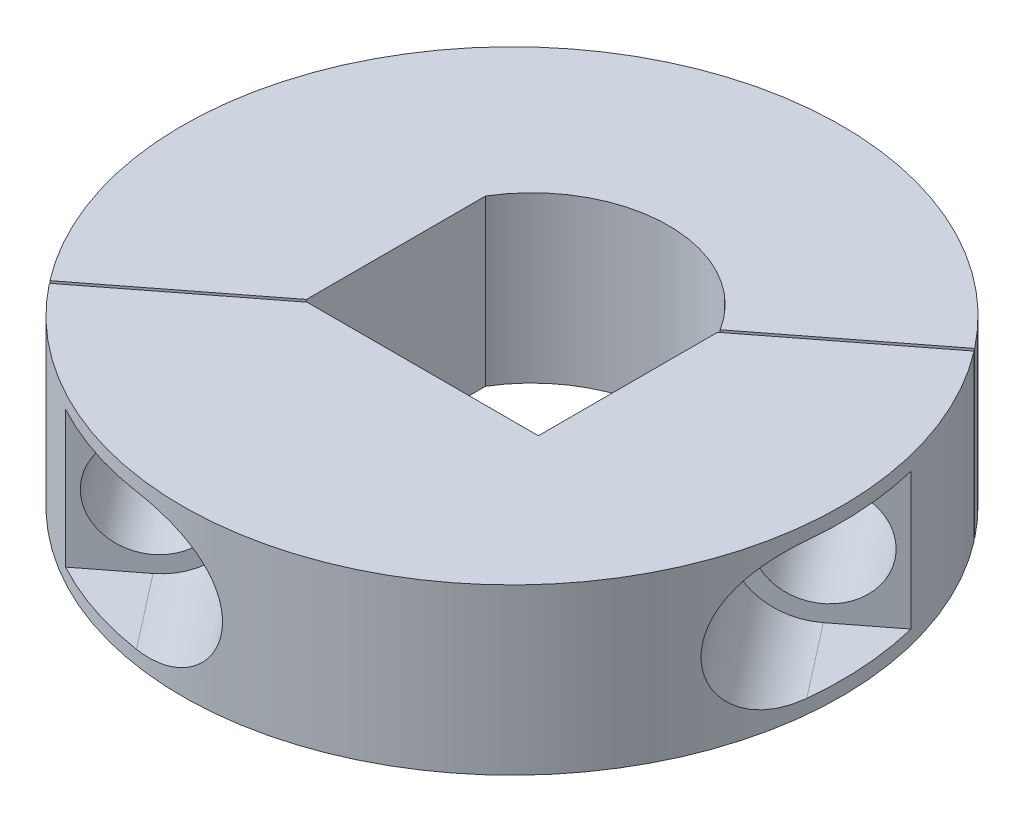
from build123d import *

# Parameters (mm, degrees)
SKETCH1_R               = 25.4
BOSS_EXTRUDE1_DEPTH     = 12.7
CUT_EXTRUDE1_DEPTH      = 13.7
CUT_EXTRUDE5_DEPTH      = 13.7
SKETCH5_R               = 4
CUT_EXTRUDE6_DEPTH      = 46.921867877
CUT_EXTRUDE6_DEPTH_BACK = 26.347867877
CUT_EXTRUDE7_DEPTH      = 26.347868027


with BuildPart() as part:
    # Sketch1 → Boss-Extrude1 (new body)
    with BuildSketch(Plane(origin=(0, 0, 0), x_dir=(1, 0, 0), z_dir=(0, 1, 0))):
        Circle(SKETCH1_R)
    extrude(amount=BOSS_EXTRUDE1_DEPTH)

    # Sketch2 → Cut-Extrude1 (cut, through all)
    with BuildSketch(Plane(origin=(0, 12.7, 0), x_dir=(1, 0, 0), z_dir=(0, 1, 0))):
        with BuildLine():
            Line((-9.017, -6.985), (9.017, -6.985))
            Line((9.017, -6.985), (9.017, 6.985))
            ThreePointArc((9.017, 6.985), (0, 12.065), (-9.017, 6.985))
            Line((-9.017, 6.985), (-9.017, -6.985))
        make_face()
    extrude(amount=-CUT_EXTRUDE1_DEPTH, mode=Mode.SUBTRACT)

    # Sketch4 → Cut-Extrude5 (cut, through all)
    with BuildSketch(Plane(origin=(0, 12.7, 0), x_dir=(1, 0, 0), z_dir=(0, 1, 0))):
        with BuildLine():
            Line((20.001939718, 15.655108033), (-20.157488744, -15.454308381))
            ThreePointArc((-20.157488744, -15.454308381), (-20.079965232, -15.554902645), (-20.001939718, -15.655108033))
            Line((-20.001939718, -15.655108033), (20.157488744, 15.454308381))
            ThreePointArc((20.157488744, 15.454308381), (20.079965232, 15.554902645), (20.001939718, 15.655108033))
        make_face()
    extrude(amount=-CUT_EXTRUDE5_DEPTH, mode=Mode.SUBTRACT)

    # Sketch5 → Cut-Extrude6 (cut, two sides)
    with BuildSketch(Plane(origin=(6.299735571, 0, 8.132385919), x_dir=(-0.790549812, 0, 0.612397742), z_dir=(-0.612397742, 0, -0.790549812))) as cut_extrude6_sk:
        with Locations((-18.409741518, 6.35)):
            Circle(SKETCH5_R)
        with Locations((18.409741518, 6.35)):
            Circle(SKETCH5_R)
    extrude(amount=CUT_EXTRUDE6_DEPTH, mode=Mode.SUBTRACT)
    extrude(cut_extrude6_sk.sketch, amount=-CUT_EXTRUDE6_DEPTH_BACK, mode=Mode.SUBTRACT)

    # Sketch6 → Cut-Extrude7 (cut, through all)
    with BuildSketch(Plane(origin=(6.299735571, 0, 8.132385919), x_dir=(-0.790549812, 0, 0.612397742), z_dir=(-0.612397742, 0, -0.790549812))):
        with BuildLine():
            Line((-18.409741518, 1.08), (-23.223643792, 1.08))
            Line((-23.223643792, 1.08), (-23.223643792, 11.62))
            Line((-23.223643792, 11.62), (-18.409741518, 11.62))
            ThreePointArc((-18.409741518, 11.62), (-13.139741518, 6.35), (-18.409741518, 1.08))
        make_face()
        with BuildLine():
            Line((23.223643792, 1.08), (23.223643792, 11.62))
            Line((23.223643792, 11.62), (18.409741518, 11.62))
            ThreePointArc((18.409741518, 11.62), (13.139741518, 6.35), (18.409741518, 1.08))
            Line((18.409741518, 1.08), (23.223643792, 1.08))
        make_face()
    extrude(amount=-CUT_EXTRUDE7_DEPTH, mode=Mode.SUBTRACT)


solid = part.part
